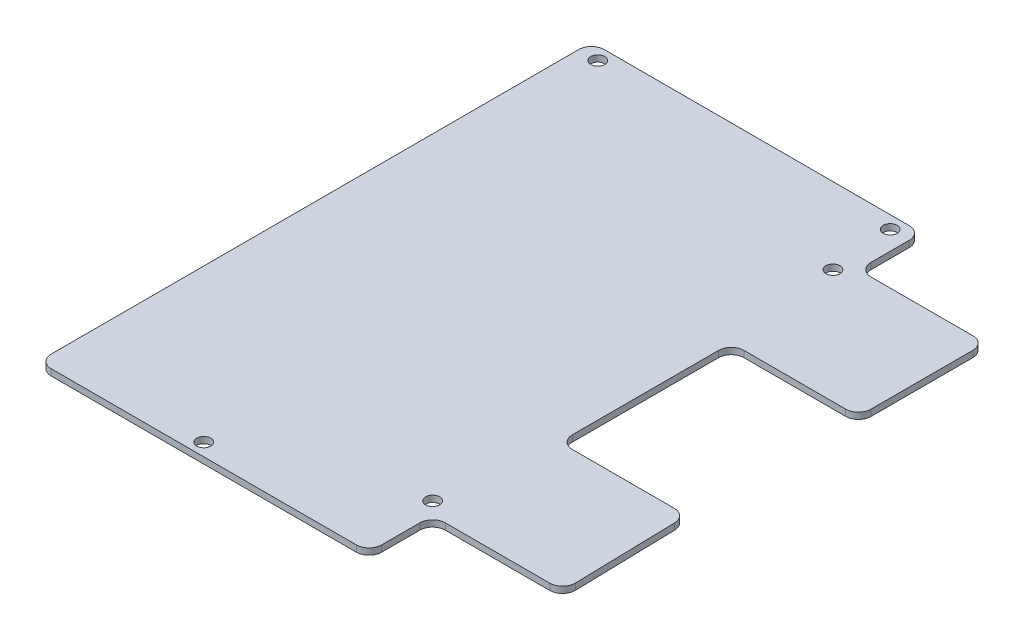
from build123d import *

# Parameters (mm, degrees)
BOSS_EXTRUDE1_DEPTH = 1
SKETCH2_R           = 1.1
CUT_EXTRUDE1_DEPTH  = 4
FILLET1_R           = 2


with BuildPart() as part:
    # Sketch1 → Boss-Extrude1 (new body)
    with BuildSketch(Plane(origin=(0, 0, 0), x_dir=(1, 0, 0), z_dir=(0, 1, 0))):
        Polygon((51.663673174, 77), (51.663673174, 87), (-0.336326826, 87), (-0.336326826, 0), (51.663673174, 0), (51.663673174, 10.002759049), (72.15352325, 10.003966236), (71.663673071, 29.997966506), (51.663673174, 30), (51.663673174, 57), (71.663673174, 57), (71.663673174, 77), align=None)
    extrude(amount=BOSS_EXTRUDE1_DEPTH)

    # Sketch2 → Cut-Extrude1 (cut)
    with BuildSketch(Plane.XZ):
        with Locations((2.663673174, -85)):
            Circle(SKETCH2_R)
        with Locations((48.663673174, -85)):
            Circle(SKETCH2_R)
        with Locations((23.663673174, -2)):
            Circle(SKETCH2_R)
        with Locations((49.663673174, -12.002641219)):
            Circle(SKETCH2_R)
        with Locations((49.663673174, -75)):
            Circle(SKETCH2_R)
    extrude(amount=-CUT_EXTRUDE1_DEPTH, mode=Mode.SUBTRACT)

    # Fillet1
    fillet1_edges = [part.edges().sort_by_distance(p)[0] for p in [
        (-0.336326826, 0.5, -87),
        (51.663673174, 0.5, -87),
        (51.663673174, 0.5, -77),
        (71.663673174, 0.5, -77),
        (71.663673174, 0.5, -57),
        (51.663673174, 0.5, -57),
        (51.663673174, 0.5, -30),
        (71.663673071, 0.5, -29.997966506),
        (72.15352325, 0.5, -10.003966236),
        (51.663673174, 0.5, -10.002759049),
        (51.663673174, 0.5, 0),
        (-0.336326826, 0.5, 0),
    ]]
    fillet(fillet1_edges, radius=FILLET1_R)


solid = part.part
